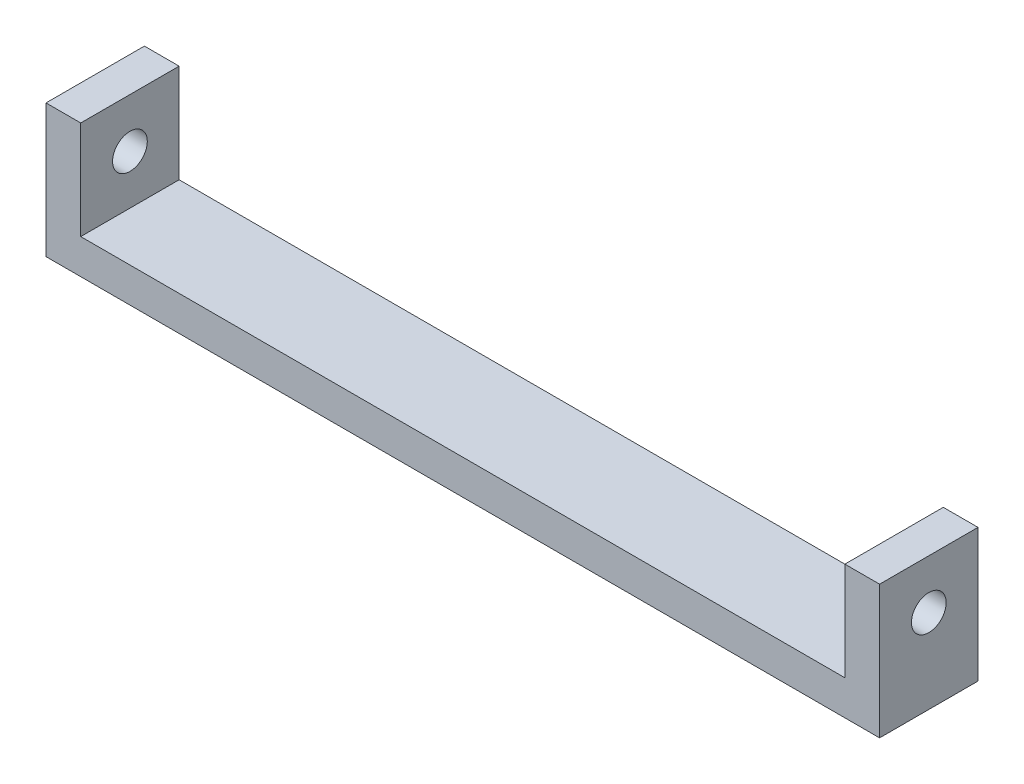
from build123d import *

# Parameters (mm, degrees)
SKETCH1_W           = 8.5
SKETCH1_H           = 8.5
BOSS_EXTRUDE1_DEPTH = 5
SKETCH2_W           = 8.5
SKETCH2_H           = 8.5
BOSS_EXTRUDE2_DEPTH = 2
SKETCH3_R           = 1.5
CUT_EXTRUDE1_DEPTH  = 2
SKETCH4_W           = 80
SKETCH4_H           = 8.5
BOSS_EXTRUDE3_DEPTH = 3
SKETCH5_W           = 7
SKETCH5_H           = 8.5
BOSS_EXTRUDE4_DEPTH = 8.5
CUT_EXTRUDE2_DEPTH  = 5
SKETCH7_R           = 1.5
CUT_EXTRUDE3_DEPTH  = 5
CUT_EXTRUDE4_DEPTH  = 10
SKETCH9_W           = 8.5
SKETCH9_H           = 8.5
SKETCH9_R           = 1.5
BOSS_EXTRUDE5_DEPTH = 2
CUT_EXTRUDE5_DEPTH  = 2
SKETCH11_W          = 8.5
SKETCH11_H          = 8.5
SKETCH11_R          = 1.5
BOSS_EXTRUDE6_DEPTH = 2
BOSS_EXTRUDE7_DEPTH = 5
BOSS_EXTRUDE8_DEPTH = 5
SKETCH14_W          = 8.5
SKETCH14_H          = 11.5
CUT_EXTRUDE6_DEPTH  = 4
SKETCH15_W          = 8.5
SKETCH15_H          = 11.5
CUT_EXTRUDE7_DEPTH  = 4
SKETCH16_R          = 1.5
CUT_EXTRUDE8_DEPTH  = 4
SKETCH17_R          = 1.5
CUT_EXTRUDE9_DEPTH  = 4


with BuildPart() as part:
    # Sketch1 → Boss-Extrude1 (new body)
    with BuildSketch(Plane(origin=(0, 0, 0), x_dir=(0, 0, -1), z_dir=(1, 0, 0))):
        Rectangle(SKETCH1_W, SKETCH1_H)
        Polygon((1.58771324, 2.75), (-1.58771324, 2.75), (-3.175426481, 0), (-1.58771324, -2.75), (1.58771324, -2.75), (3.175426481, 0), align=None, mode=Mode.SUBTRACT)
    extrude(amount=BOSS_EXTRUDE1_DEPTH)

    # Sketch2 → Boss-Extrude2 (add)
    with BuildSketch(Plane.ZY):
        Rectangle(SKETCH2_W, SKETCH2_H)
    extrude(amount=BOSS_EXTRUDE2_DEPTH)

    # Sketch3 → Cut-Extrude1 (cut)
    with BuildSketch(Plane(origin=(0, 0, 0), x_dir=(0, 0, -1), z_dir=(1, 0, 0))):
        Circle(SKETCH3_R)
    extrude(amount=-CUT_EXTRUDE1_DEPTH, mode=Mode.SUBTRACT)

    # Sketch4 → Boss-Extrude3 (add)
    with BuildSketch(Plane.XZ.offset(4.25)):
        with Locations((38, 0)):
            Rectangle(SKETCH4_W, SKETCH4_H)
    extrude(amount=BOSS_EXTRUDE3_DEPTH)

    # Sketch5 → Boss-Extrude4 (add)
    with BuildSketch(Plane(origin=(0, -4.25, 0), x_dir=(1, 0, 0), z_dir=(0, 1, 0))):
        with Locations((74.5, 0)):
            Rectangle(SKETCH5_W, SKETCH5_H)
    extrude(amount=BOSS_EXTRUDE4_DEPTH)

    # Sketch6 → Cut-Extrude2 (cut)
    with BuildSketch(Plane.ZY.offset(-71)):
        Polygon((3.175426481, 0), (1.58771324, 2.75), (-1.58771324, 2.75), (-3.175426481, 0), (-1.58771324, -2.75), (1.58771324, -2.75), align=None)
    extrude(amount=-CUT_EXTRUDE2_DEPTH, mode=Mode.SUBTRACT)

    # Sketch7 → Cut-Extrude3 (cut)
    with BuildSketch(Plane.ZY.offset(-76)):
        Circle(SKETCH7_R)
    extrude(amount=-CUT_EXTRUDE3_DEPTH, mode=Mode.SUBTRACT)

    # Sketch8 → Cut-Extrude4 (cut)
    with BuildSketch(Plane.ZY.offset(2)):
        Polygon((-1.58771324, 2.75), (1.58771324, 2.75), (3.175426481, 0), (1.58771324, -2.75), (-1.58771324, -2.75), (-3.175426481, 0), align=None)
    extrude(amount=-CUT_EXTRUDE4_DEPTH, mode=Mode.SUBTRACT)

    # Sketch9 → Boss-Extrude5 (add)
    with BuildSketch(Plane(origin=(5, 0, 0), x_dir=(0, 0, -1), z_dir=(1, 0, 0))):
        Rectangle(SKETCH9_W, SKETCH9_H)
        Circle(SKETCH9_R, mode=Mode.SUBTRACT)
    extrude(amount=-BOSS_EXTRUDE5_DEPTH)

    # Sketch10 → Cut-Extrude5 (cut)
    with BuildSketch(Plane(origin=(78, 0, 0), x_dir=(0, 0, -1), z_dir=(1, 0, 0))):
        Polygon((-3.175426481, 0), (-1.58771324, 2.75), (1.58771324, 2.75), (3.175426481, 0), (1.58771324, -2.75), (-1.58771324, -2.75), align=None)
    extrude(amount=-CUT_EXTRUDE5_DEPTH, mode=Mode.SUBTRACT)

    # Sketch11 → Boss-Extrude6 (add)
    with BuildSketch(Plane.ZY.offset(-71)):
        Rectangle(SKETCH11_W, SKETCH11_H)
        Circle(SKETCH11_R, mode=Mode.SUBTRACT)
    extrude(amount=-BOSS_EXTRUDE6_DEPTH)

    # Sketch12 → Boss-Extrude7 (add)
    with BuildSketch(Plane.ZY.offset(-3)):
        Polygon((-3.175426481, 0), (-1.58771324, 2.75), (1.58771324, 2.75), (3.175426481, 0), (1.58771324, -2.75), (-1.58771324, -2.75), align=None)
    extrude(amount=BOSS_EXTRUDE7_DEPTH)

    # Sketch13 → Boss-Extrude8 (add)
    with BuildSketch(Plane(origin=(73, 0, 0), x_dir=(0, 0, -1), z_dir=(1, 0, 0))):
        Polygon((-1.58771324, 2.75), (-3.175426481, 0), (-1.58771324, -2.75), (1.58771324, -2.75), (3.175426481, 0), (1.58771324, 2.75), align=None)
    extrude(amount=BOSS_EXTRUDE8_DEPTH)

    # Sketch14 → Cut-Extrude6 (cut)
    with BuildSketch(Plane.ZY.offset(2)):
        with Locations((0, -1.5)):
            Rectangle(SKETCH14_W, SKETCH14_H)
    extrude(amount=-CUT_EXTRUDE6_DEPTH, mode=Mode.SUBTRACT)

    # Sketch15 → Cut-Extrude7 (cut)
    with BuildSketch(Plane(origin=(78, 0, 0), x_dir=(0, 0, -1), z_dir=(1, 0, 0))):
        with Locations((0, -1.5)):
            Rectangle(SKETCH15_W, SKETCH15_H)
    extrude(amount=-CUT_EXTRUDE7_DEPTH, mode=Mode.SUBTRACT)

    # Sketch16 → Cut-Extrude8 (cut)
    with BuildSketch(Plane(origin=(5, 0, 0), x_dir=(0, 0, -1), z_dir=(1, 0, 0))):
        Circle(SKETCH16_R)
    extrude(amount=-CUT_EXTRUDE8_DEPTH, mode=Mode.SUBTRACT)

    # Sketch17 → Cut-Extrude9 (cut)
    with BuildSketch(Plane.ZY.offset(-73)):
        Circle(SKETCH17_R)
    extrude(amount=-CUT_EXTRUDE9_DEPTH, mode=Mode.SUBTRACT)


solid = part.part
